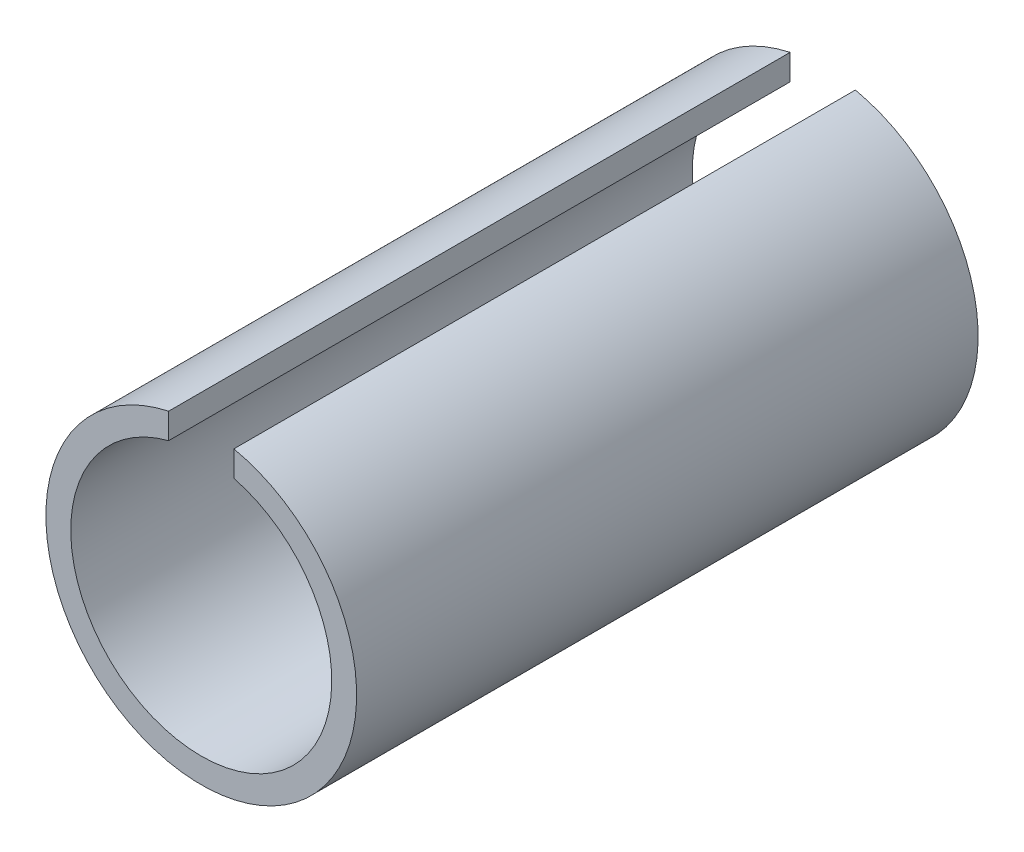
from build123d import *

# Parameters (mm, degrees)
BOSS_EXTRUDE1_DEPTH = 19.05


with BuildPart() as part:
    # Sketch1 → Boss-Extrude1 (new body)
    with BuildSketch(Plane.XY):
        with BuildLine():
            Line((-1, 3.872983346), (-1, 4.656329697))
            ThreePointArc((-1, 4.656329697), (0, -4.7625), (1, 4.656329697))
            Line((1, 4.656329697), (1, 3.872983346))
            ThreePointArc((1, 3.872983346), (0, -4), (-1, 3.872983346))
        make_face()
    extrude(amount=BOSS_EXTRUDE1_DEPTH)


solid = part.part
